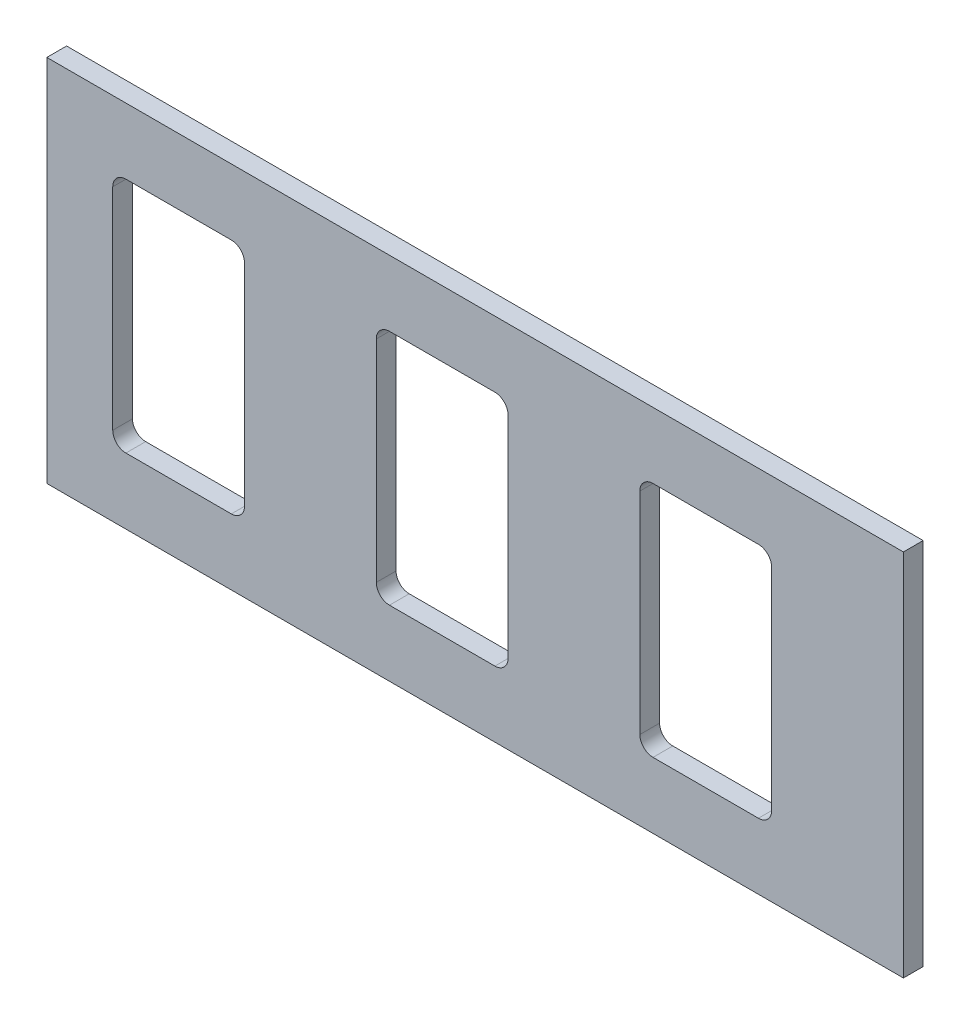
from build123d import *

# Parameters (mm, degrees)
SKETCH1_W           = 130
SKETCH1_H           = 56
BOSS_EXTRUDE1_DEPTH = 3
SKETCH2_W           = 20
SKETCH2_H           = 36
CUT_EXTRUDE1_DEPTH  = 5
FILLET1_R           = 2


with BuildPart() as part:
    # Sketch1 → Boss-Extrude1 (new body)
    with BuildSketch(Plane.XY):
        Rectangle(SKETCH1_W, SKETCH1_H)
    extrude(amount=BOSS_EXTRUDE1_DEPTH)

    # Sketch2 → Cut-Extrude1 (cut)
    with BuildSketch(Plane.XY.offset(3)):
        with Locations((35, 0)):
            Rectangle(SKETCH2_W, SKETCH2_H)
        with Locations((-5, 0)):
            Rectangle(SKETCH2_W, SKETCH2_H)
        with Locations((-45, 0)):
            Rectangle(SKETCH2_W, SKETCH2_H)
    extrude(amount=-CUT_EXTRUDE1_DEPTH, mode=Mode.SUBTRACT)

    # Fillet1
    fillet1_edges = [part.edges().sort_by_distance(p)[0] for p in [
        (5, -18, 1.5),
        (-15, -18, 1.5),
        (-15, 18, 1.5),
        (5, 18, 1.5),
        (-55, 18, 1.5),
        (-35, 18, 1.5),
        (-35, -18, 1.5),
        (-55, -18, 1.5),
        (25, 18, 1.5),
        (45, 18, 1.5),
        (45, -18, 1.5),
        (25, -18, 1.5),
    ]]
    fillet(fillet1_edges, radius=FILLET1_R)


solid = part.part
